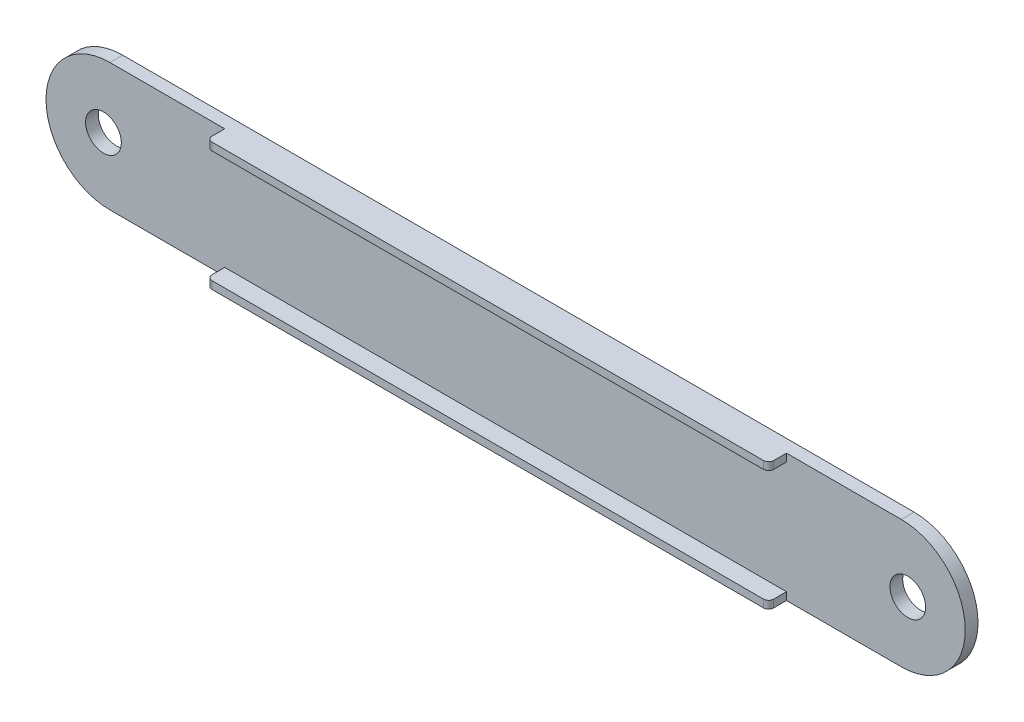
from build123d import *

# Parameters (mm, degrees)
BOSS_EXTRUDE1_DEPTH = 5
SKETCH3_W           = 220
SKETCH3_H           = 3
BOSS_EXTRUDE2_DEPTH = 7
SKETCH4_R           = 7
CUT_EXTRUDE1_DEPTH  = 7
CUT_EXTRUDE2_DEPTH  = 70


with BuildPart() as part:
    # Sketch2 → Boss-Extrude1 (new body)
    with BuildSketch(Plane.XY):
        with BuildLine():
            Line((-142.959039548, 32.18220339), (167.040960452, 32.18220339))
            ThreePointArc((167.040960452, 32.18220339), (192.040960452, 7.18220339), (167.040960452, -17.81779661))
            Line((167.040960452, -17.81779661), (-142.959039548, -17.81779661))
            ThreePointArc((-142.959039548, -17.81779661), (-167.959039548, 7.18220339), (-142.959039548, 32.18220339))
        make_face()
    extrude(amount=BOSS_EXTRUDE1_DEPTH)

    # Sketch3 → Boss-Extrude2 (add)
    with BuildSketch(Plane.XY.offset(5)):
        with Locations((12.040960452, 30.68220339)):
            Rectangle(SKETCH3_W, SKETCH3_H)
        with Locations((12.040960452, -16.31779661)):
            Rectangle(SKETCH3_W, SKETCH3_H)
    extrude(amount=BOSS_EXTRUDE2_DEPTH)

    # Sketch4 → Cut-Extrude1 (cut)
    with BuildSketch(Plane.XY.offset(5)):
        with Locations((-145.459039548, 7.18220339)):
            Circle(SKETCH4_R)
        with Locations((169.540960452, 7.18220339)):
            Circle(SKETCH4_R)
    extrude(amount=-CUT_EXTRUDE1_DEPTH, mode=Mode.SUBTRACT)

    # Sketch5 → Cut-Extrude2 (cut)
    with BuildSketch(Plane.XZ.offset(17.81779661)):
        with BuildLine():
            ThreePointArc((-97.959039548, 10), (-97.37325311, 11.414213562), (-95.959039548, 12))
            Line((-95.959039548, 12), (-97.959039548, 12))
            Line((-97.959039548, 12), (-97.959039548, 10))
        make_face()
        with BuildLine():
            Line((122.040960452, 12), (120.040960452, 12))
            ThreePointArc((120.040960452, 12), (121.455174014, 11.414213562), (122.040960452, 10))
            Line((122.040960452, 10), (122.040960452, 12))
        make_face()
    extrude(amount=-CUT_EXTRUDE2_DEPTH, mode=Mode.SUBTRACT)


solid = part.part
